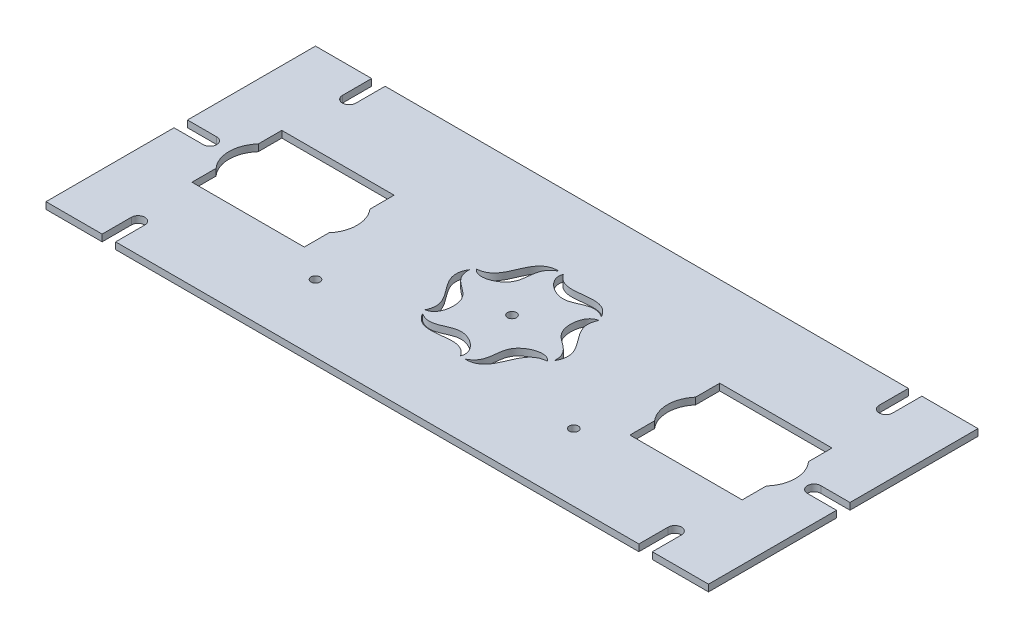
from build123d import *

# Parameters (mm, degrees)
SKETCH1_W           = 295
SKETCH1_H           = 120
BOSS_EXTRUDE1_DEPTH = 3
CUT_EXTRUDE1_DEPTH  = 10
SKETCH3_R           = 2
CUT_EXTRUDE3_DEPTH  = 10
SKETCH4_W           = 50
SKETCH4_H           = 40
CUT_EXTRUDE4_DEPTH  = 10
CUT_EXTRUDE5_DEPTH  = 10
SKETCH7_R           = 2
CUT_EXTRUDE6_DEPTH  = 10


with BuildPart() as part:
    # Sketch1 → Boss-Extrude1 (new body)
    with BuildSketch(Plane(origin=(0, 0, 0), x_dir=(1, 0, 0), z_dir=(0, 1, 0))):
        Rectangle(SKETCH1_W, SKETCH1_H)
    extrude(amount=BOSS_EXTRUDE1_DEPTH)

    # Sketch2 → Cut-Extrude1 (cut)
    with BuildSketch(Plane(origin=(0, 3, 0), x_dir=(1, 0, 0), z_dir=(0, 1, 0))):
        with BuildLine():
            Line((-122.5, 60), (-122.5, 47))
            ThreePointArc((-122.5, 47), (-119.5, 44), (-116.5, 47))
            Line((-116.5, 47), (-116.5, 60))
            Line((-116.5, 60), (-122.5, 60))
        make_face()
        with BuildLine():
            Line((116.5, 60), (122.5, 60))
            Line((122.5, 60), (122.5, 47))
            ThreePointArc((122.5, 47), (119.5, 44), (116.5, 47))
            Line((116.5, 47), (116.5, 60))
        make_face()
        with BuildLine():
            Line((122.5, -60), (122.5, -47))
            ThreePointArc((122.5, -47), (119.5, -44), (116.5, -47))
            Line((116.5, -47), (116.5, -60))
            Line((116.5, -60), (122.5, -60))
        make_face()
        with BuildLine():
            Line((-116.5, -60), (-122.5, -60))
            Line((-122.5, -60), (-122.5, -47))
            ThreePointArc((-122.5, -47), (-119.5, -44), (-116.5, -47))
            Line((-116.5, -47), (-116.5, -60))
        make_face()
        with BuildLine():
            Line((147.5, 3), (134.5, 3))
            ThreePointArc((134.5, 3), (131.5, 0), (134.5, -3))
            Line((134.5, -3), (147.5, -3))
            Line((147.5, -3), (147.5, 3))
        make_face()
        with BuildLine():
            Line((-147.5, -3), (-147.5, 3))
            Line((-147.5, 3), (-134.5, 3))
            ThreePointArc((-134.5, 3), (-131.5, 0), (-134.5, -3))
            Line((-134.5, -3), (-147.5, -3))
        make_face()
    extrude(amount=-CUT_EXTRUDE1_DEPTH, mode=Mode.SUBTRACT)

    # Sketch3 → Cut-Extrude3 (cut)
    with BuildSketch(Plane(origin=(0, 3, 0), x_dir=(1, 0, 0), z_dir=(0, 1, 0))):
        Circle(SKETCH3_R)
        with BuildLine():
            add(Edge.make_bspline(
                [(-6.410344093, 27.417141588), (-18.670293307, 27.60414968), (-14.25864482, 10.560229341), (-25.694680872, 9.902518278)],
                knots=[0, 0, 0, 0, 1, 1, 1, 1], degree=3))
            add(Edge.make_bspline(
                [(-25.694680872, 9.902518278), (-22.747479851, 6.072382582), (-7.175512188, 11.94255773), (-13.199821367, 24.03169012), (-6.410344093, 27.417141588)],
                knots=[0, 0, 0, 0, 0.463038322, 1, 1, 1, 1], degree=3))
        make_face()
        with BuildLine():
            add(Edge.make_bspline(
                [(-4.271508046, 27.203505516), (-6.114902348, 22.736086714), (6.754802286, 12.185454705), (14.212143456, 23.447225689), (20.538769068, 19.260091626)],
                knots=[0, 0, 0, 0, 0.463038322, 1, 1, 1, 1], degree=3))
            add(Edge.make_bspline(
                [(20.538769068, 19.260091626), (14.570748219, 29.97102314), (2.016104469, 17.628463309), (-4.271508046, 27.203505516)],
                knots=[0, 0, 0, 0, 1, 1, 1, 1], degree=3))
        make_face()
        with BuildLine():
            add(Edge.make_bspline(
                [(21.423172826, 17.300987239), (16.632577503, 16.663704132), (13.930314474, 0.242896975), (27.411964823, -0.584464431), (26.949113161, -8.157049963)],
                knots=[0, 0, 0, 0, 0.463038322, 1, 1, 1, 1], degree=3))
            add(Edge.make_bspline(
                [(26.949113161, -8.157049963), (33.241041526, 2.36687346), (16.27474929, 7.068233967), (21.423172826, 17.300987239)],
                knots=[0, 0, 0, 0, 1, 1, 1, 1], degree=3))
        make_face()
        with BuildLine():
            add(Edge.make_bspline(
                [(25.694680872, -9.902518278), (22.747479851, -6.072382582), (7.175512188, -11.94255773), (13.199821367, -24.03169012), (6.410344093, -27.417141588)],
                knots=[0, 0, 0, 0, 0.463038322, 1, 1, 1, 1], degree=3))
            add(Edge.make_bspline(
                [(6.410344093, -27.417141588), (18.670293307, -27.60414968), (14.25864482, -10.560229341), (25.694680872, -9.902518278)],
                knots=[0, 0, 0, 0, 1, 1, 1, 1], degree=3))
        make_face()
        with BuildLine():
            add(Edge.make_bspline(
                [(4.271508046, -27.203505516), (6.114902348, -22.736086714), (-6.754802286, -12.185454705), (-14.212143456, -23.447225689), (-20.538769068, -19.260091626)],
                knots=[0, 0, 0, 0, 0.463038322, 1, 1, 1, 1], degree=3))
            add(Edge.make_bspline(
                [(-20.538769068, -19.260091626), (-14.570748219, -29.97102314), (-2.016104469, -17.628463309), (4.271508046, -27.203505516)],
                knots=[0, 0, 0, 0, 1, 1, 1, 1], degree=3))
        make_face()
        with BuildLine():
            add(Edge.make_bspline(
                [(-21.423172826, -17.300987239), (-16.632577503, -16.663704132), (-13.930314474, -0.242896975), (-27.411964823, 0.584464431), (-26.949113161, 8.157049963)],
                knots=[0, 0, 0, 0, 0.463038322, 1, 1, 1, 1], degree=3))
            add(Edge.make_bspline(
                [(-26.949113161, 8.157049963), (-33.241041526, -2.36687346), (-16.27474929, -7.068233967), (-21.423172826, -17.300987239)],
                knots=[0, 0, 0, 0, 1, 1, 1, 1], degree=3))
        make_face()
    extrude(amount=-CUT_EXTRUDE3_DEPTH, mode=Mode.SUBTRACT)

    # Sketch4 → Cut-Extrude4 (cut)
    with BuildSketch(Plane(origin=(0, 3, 0), x_dir=(1, 0, 0), z_dir=(0, 1, 0))):
        with Locations((-97.5, 0)):
            Rectangle(SKETCH4_W, SKETCH4_H)
        with Locations((97.5, 0)):
            Rectangle(SKETCH4_W, SKETCH4_H)
    extrude(amount=-CUT_EXTRUDE4_DEPTH, mode=Mode.SUBTRACT)

    # Sketch5 → Cut-Extrude5 (cut)
    with BuildSketch(Plane.XZ):
        with BuildLine():
            ThreePointArc((-72.5, -2.972696437), (-72.219152944, -1.561140662), (-72.125, -0.125))
            ThreePointArc((-72.125, -0.125), (-72.219152944, 1.311140662), (-72.5, 2.722696437))
            Line((-72.5, 2.722696437), (-72.5, -2.972696437))
        make_face()
        with BuildLine():
            Line((-72.5, -2.972696437), (-72.5, 2.722696437))
            ThreePointArc((-72.5, 2.722696437), (-94.125, -0.125), (-72.5, -2.972696437))
        make_face()
        with BuildLine():
            ThreePointArc((-122.5, -3.780047879), (-110.270950378, -10.967624221), (-101.125, -0.125))
            ThreePointArc((-101.125, -0.125), (-110.270950378, 10.717624221), (-122.5, 3.530047879))
            Line((-122.5, 3.530047879), (-122.5, -3.780047879))
        make_face()
        with BuildLine():
            Line((-122.5, -3.780047879), (-122.5, 3.530047879))
            ThreePointArc((-122.5, 3.530047879), (-123.125, -0.125), (-122.5, -3.780047879))
        make_face()
        with BuildLine():
            ThreePointArc((-122.5, 3.530047879), (-110.270950378, 10.717624221), (-101.125, -0.125))
            ThreePointArc((-101.125, -0.125), (-110.270950378, -10.967624221), (-122.5, -3.780047879))
            Line((-122.5, -3.780047879), (-122.5, -9.524966755))
            ThreePointArc((-122.5, -9.524966755), (-107.08763958, -13.187350478), (-98.125, -0.125))
            ThreePointArc((-98.125, -0.125), (-107.08763958, 12.937350478), (-122.5, 9.274966755))
            Line((-122.5, 9.274966755), (-122.5, 3.530047879))
        make_face()
        with BuildLine():
            ThreePointArc((-122.5, -3.780047879), (-123.125, -0.125), (-122.5, 3.530047879))
            Line((-122.5, 3.530047879), (-122.5, 9.274966755))
            ThreePointArc((-122.5, 9.274966755), (-126.125, -0.125), (-122.5, -9.524966755))
            Line((-122.5, -9.524966755), (-122.5, -3.780047879))
        make_face()
        with BuildLine():
            ThreePointArc((-72.5, 2.722696437), (-72.219152944, 1.311140662), (-72.125, -0.125))
            ThreePointArc((-72.125, -0.125), (-72.219152944, -1.561140662), (-72.5, -2.972696437))
            Line((-72.5, -2.972696437), (-72.5, -9.241434336))
            ThreePointArc((-72.5, -9.241434336), (-69.995833994, -4.985555524), (-69.125, -0.125))
            ThreePointArc((-69.125, -0.125), (-69.995833994, 4.735555524), (-72.5, 8.991434336))
            Line((-72.5, 8.991434336), (-72.5, 2.722696437))
        make_face()
        with BuildLine():
            ThreePointArc((-72.5, -2.972696437), (-94.125, -0.125), (-72.5, 2.722696437))
            Line((-72.5, 2.722696437), (-72.5, 8.991434336))
            ThreePointArc((-72.5, 8.991434336), (-97.125, -0.125), (-72.5, -9.241434336))
            Line((-72.5, -9.241434336), (-72.5, -2.972696437))
        make_face()
    cut_extrude5 = extrude(amount=-CUT_EXTRUDE5_DEPTH, mode=Mode.SUBTRACT)

    # Mirror1: Cut-Extrude5 across plane
    add(cut_extrude5.mirror(Plane(origin=(0, 0, 0), x_dir=(0, 0, 1), z_dir=(1, 0, 0))), mode=Mode.SUBTRACT)

    # Sketch7 → Cut-Extrude6 (cut)
    with BuildSketch(Plane.XZ):
        with Locations((57.5, 30)):
            Circle(SKETCH7_R)
        with Locations((-57.5, 30)):
            Circle(SKETCH7_R)
    extrude(amount=-CUT_EXTRUDE6_DEPTH, mode=Mode.SUBTRACT)


solid = part.part
